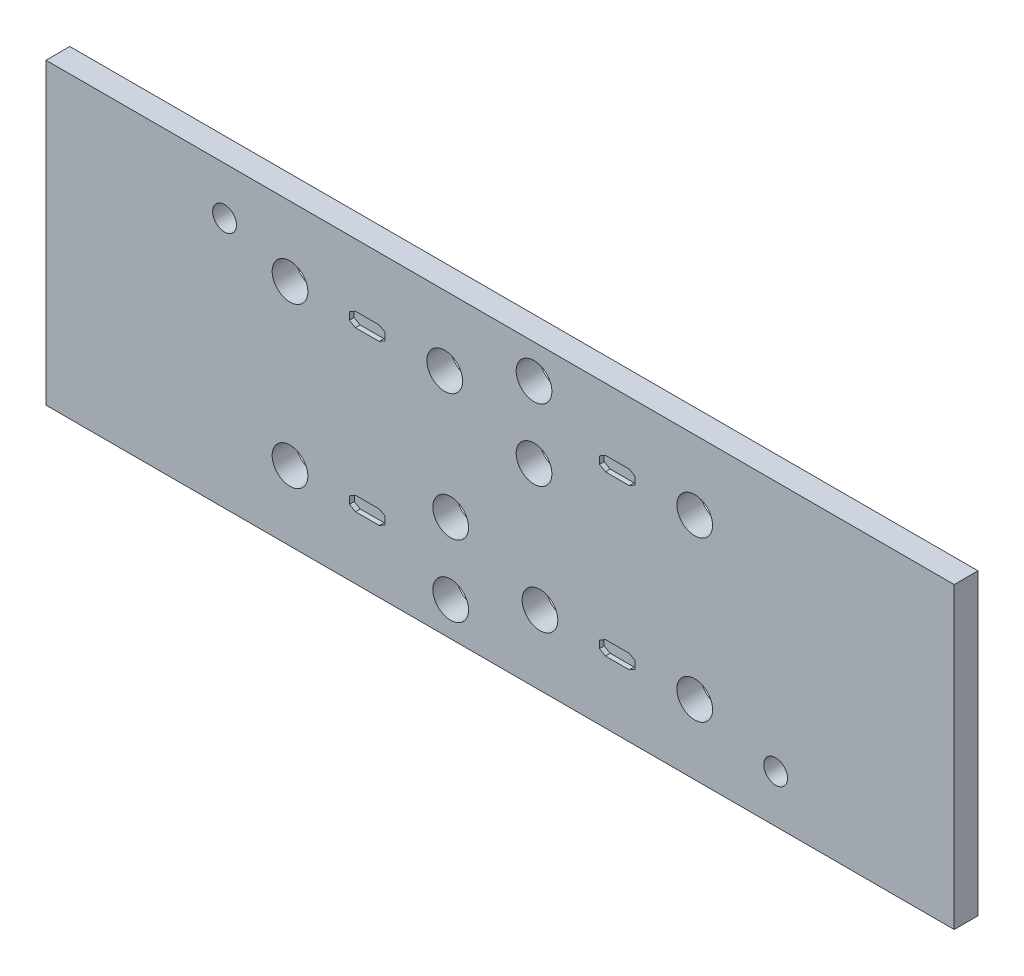
from build123d import *

# Parameters (mm, degrees)
SKETCH1_W           = 76.3
SKETCH1_H           = 25.1
BOSS_EXTRUDE1_DEPTH = 2
SKETCH3_R           = 1
CUT_EXTRUDE2_DEPTH  = 10
SKETCH10_R          = 1.5
CUT_EXTRUDE8_DEPTH  = 2
CUT_EXTRUDE10_DEPTH = 0.4


with BuildPart() as part:
    # Sketch1 → Boss-Extrude1 (new body)
    with BuildSketch(Plane.XY):
        with Locations((38.15, 12.55)):
            Rectangle(SKETCH1_W, SKETCH1_H)
    extrude(amount=BOSS_EXTRUDE1_DEPTH)

    # Sketch3 → Cut-Extrude2 (cut)
    with BuildSketch(Plane.XY.offset(2)):
        with Locations((15, 21.1)):
            Circle(SKETCH3_R)
        with Locations((61.3, 4)):
            Circle(SKETCH3_R)
    extrude(amount=-CUT_EXTRUDE2_DEPTH, mode=Mode.SUBTRACT)

    # Sketch10 → Cut-Extrude8 (cut)
    with BuildSketch(Plane.XY.offset(2)):
        with Locations((20.5, 19.25108338)):
            Circle(SKETCH10_R)
        with Locations((20.5, 5.84891662)):
            Circle(SKETCH10_R)
        with Locations((54.5, 5.84891662)):
            Circle(SKETCH10_R)
        with Locations((54.5, 19.25108338)):
            Circle(SKETCH10_R)
        with Locations((33.5, 19.25108338)):
            Circle(SKETCH10_R)
        with Locations((41.5, 5.84891662)):
            Circle(SKETCH10_R)
        with Locations((34, 2.85)):
            Circle(SKETCH10_R)
        with Locations((34, 8.85)):
            Circle(SKETCH10_R)
        with Locations((41, 22.25)):
            Circle(SKETCH10_R)
        with Locations((41, 16.25)):
            Circle(SKETCH10_R)
    extrude(amount=-CUT_EXTRUDE8_DEPTH, mode=Mode.SUBTRACT)

    # Sketch12 → Cut-Extrude10 (cut)
    with BuildSketch(Plane.XY.offset(2)):
        Polygon((25.986752225, 19.834512657), (27.986752225, 19.834512657), (28.486752225, 19.545837522), (28.486752225, 18.923187791), (27.986752225, 18.634512657), (25.986752225, 18.634512657), (25.486752225, 18.923187791), (25.486752225, 19.545837522), align=None)
        Polygon((49.5, 6.15891662), (49.5, 5.53691662), (48.999437317, 5.24791662), (46.999437317, 5.24791662), (46.5, 5.537566351), (46.5, 6.159566351), (46.999437317, 6.44791662), (48.999437317, 6.44791662), align=None)
        Polygon((25.5, 6.159566351), (25.5, 5.537566351), (26.000562683, 5.248566351), (28.000562683, 5.248566351), (28.5, 5.537566351), (28.5, 6.160216081), (28.000562683, 6.448566351), (26.000562683, 6.448566351), align=None)
        Polygon((49.5, 19.56308338), (49.5, 18.94108338), (48.999437317, 18.65208338), (46.999437317, 18.65208338), (46.498874633, 18.94108338), (46.498874633, 19.56308338), (46.999437317, 19.85208338), (48.999437317, 19.85208338), align=None)
    extrude(amount=-CUT_EXTRUDE10_DEPTH, mode=Mode.SUBTRACT)


solid = part.part
